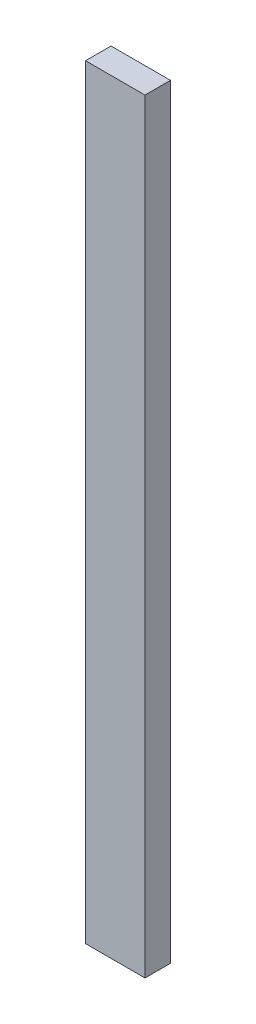
from build123d import *

# Parameters (mm, degrees)
SKETCH1_W           = 88.9
SKETCH1_H           = 38.1
BOSS_EXTRUDE1_DEPTH = 1143


with BuildPart() as part:
    # Sketch1 → Boss-Extrude1 (new body)
    with BuildSketch(Plane(origin=(0, 0, 0), x_dir=(1, 0, 0), z_dir=(0, 1, 0))):
        Rectangle(SKETCH1_W, SKETCH1_H)
    extrude(amount=BOSS_EXTRUDE1_DEPTH)


solid = part.part
